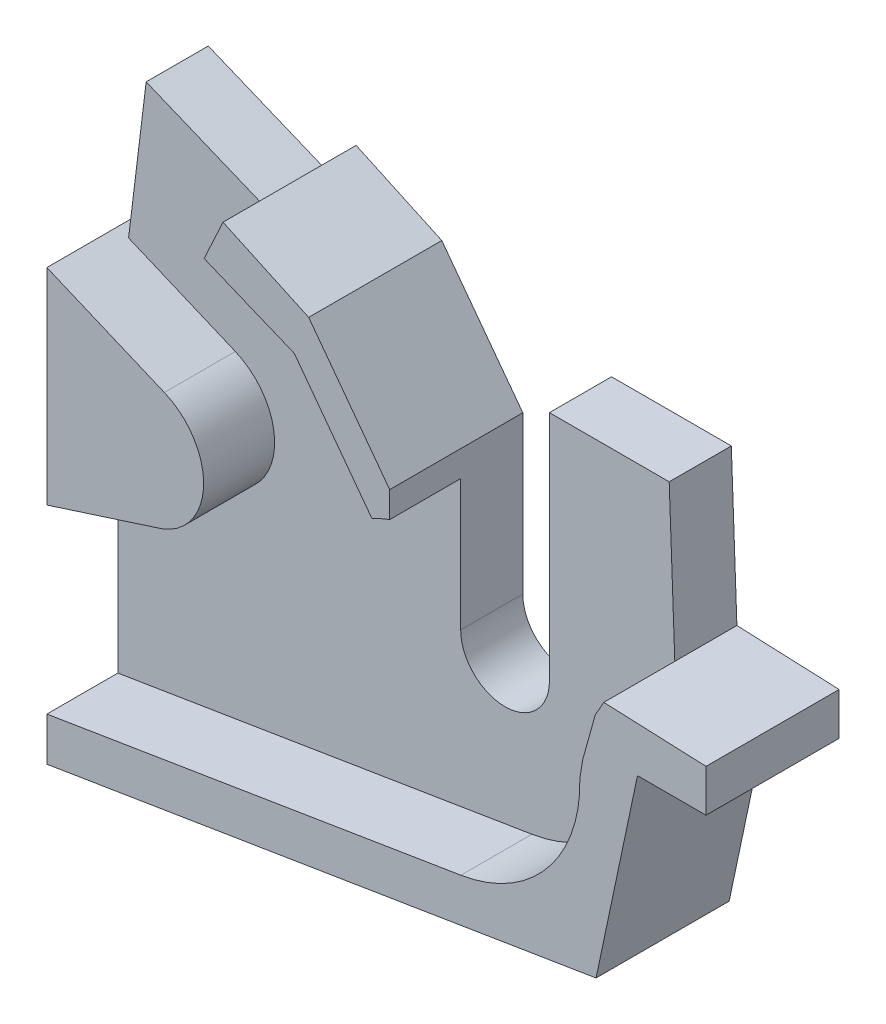
from build123d import *

# Parameters (mm, degrees)
BOSS_EXTRUDE2_DEPTH = 7
BOSS_EXTRUDE3_DEPTH = 15


with BuildPart() as part:
    # Sketch1 → Boss-Extrude2 (new body)
    with BuildSketch(Plane.XY):
        with BuildLine():
            Line((-39.542433315, -25.583271541), (22.35186865, -15.501296132))
            Line((22.35186865, -15.501296132), (27.018997021, 6.583034036))
            Line((27.018997021, 6.583034036), (34.744303123, 6.583034036))
            Line((34.744303123, 6.583034036), (34.744303123, 11.354641566))
            Line((34.744303123, 11.354641566), (23.2245968, 11.838054321))
            Line((23.2245968, 11.838054321), (22.594616957, 29.052034329))
            Line((22.594616957, 29.052034329), (9.094616957, 29.052034329))
            Line((9.094616957, 29.052034329), (9.094616957, 2.846901584))
            ThreePointArc((9.094616957, 2.846901584), (4.094616957, -2.153098416), (-0.905383043, 2.846901584))
            Line((-0.905383043, 2.846901584), (-0.905383043, 20.539136331))
            Line((-0.905383043, 20.539136331), (-10.036820206, 32.783811613))
            Line((-10.036820206, 32.783811613), (-19.690097484, 37.247946124))
            Line((-19.690097484, 37.247946124), (-21.821876557, 32.638171386))
            Line((-21.821876557, 32.638171386), (-36.353312831, 38.611972459))
            Line((-36.353312831, 38.611972459), (-39.542433315, 12.487268255))
            Line((-39.542433315, 12.487268255), (-39.542433315, -25.583271541))
        make_face()
    extrude(amount=BOSS_EXTRUDE2_DEPTH)

    # Sketch1_7 → Boss-Extrude3 (add)
    with BuildSketch(Plane.XY):
        with BuildLine():
            Line((-39.542433315, -20.685958376), (-39.542433315, -25.583271541))
            Line((-39.542433315, -25.583271541), (22.35186865, -15.501296132))
            Line((22.35186865, -15.501296132), (27.018997021, 6.583034036))
            Line((27.018997021, 6.583034036), (34.744303123, 6.583034036))
            Line((34.744303123, 6.583034036), (34.744303123, 11.354641566))
            Line((34.744303123, 11.354641566), (23.2245968, 11.838054321))
            Line((23.2245968, 11.838054321), (22.257186267, 10.122973627))
            Line((22.257186267, 10.122973627), (20.850125794, 5.080010211))
            Line((20.850125794, 5.080010211), (20.523303512, 3.077207951))
            ThreePointArc((20.523303512, 3.077207951), (16.858734445, -7.523493754), (7.118615678, -13.085330635))
            Line((7.118615678, -13.085330635), (-39.542433315, -20.685958376))
        make_face()
        with BuildLine():
            Line((-39.542433315, 22.895355765), (-39.542433315, -0.287420009))
            Line((-39.542433315, -0.287420009), (-26.432254104, 3.928552647))
            ThreePointArc((-26.432254104, 3.928552647), (-21.876232947, 10.580960298), (-26.303625242, 17.319658526))
            Line((-26.303625242, 17.319658526), (-39.542433315, 22.895355765))
        make_face()
        with BuildLine():
            Line((-11.654155817, 28.458272035), (-2.910814831, 16.713787882))
            ThreePointArc((-2.910814831, 16.713787882), (-1.923594587, 17.19744001), (-0.905383043, 17.611889578))
            Line((-0.905383043, 17.611889578), (-0.905383043, 20.539136331))
            Line((-0.905383043, 20.539136331), (-10.036820206, 32.783811613))
            Line((-10.036820206, 32.783811613), (-19.690097484, 37.247946124))
            Line((-19.690097484, 37.247946124), (-21.821876557, 32.638171386))
            Line((-21.821876557, 32.638171386), (-11.654155817, 28.458272035))
        make_face()
    extrude(amount=BOSS_EXTRUDE3_DEPTH)


solid = part.part
